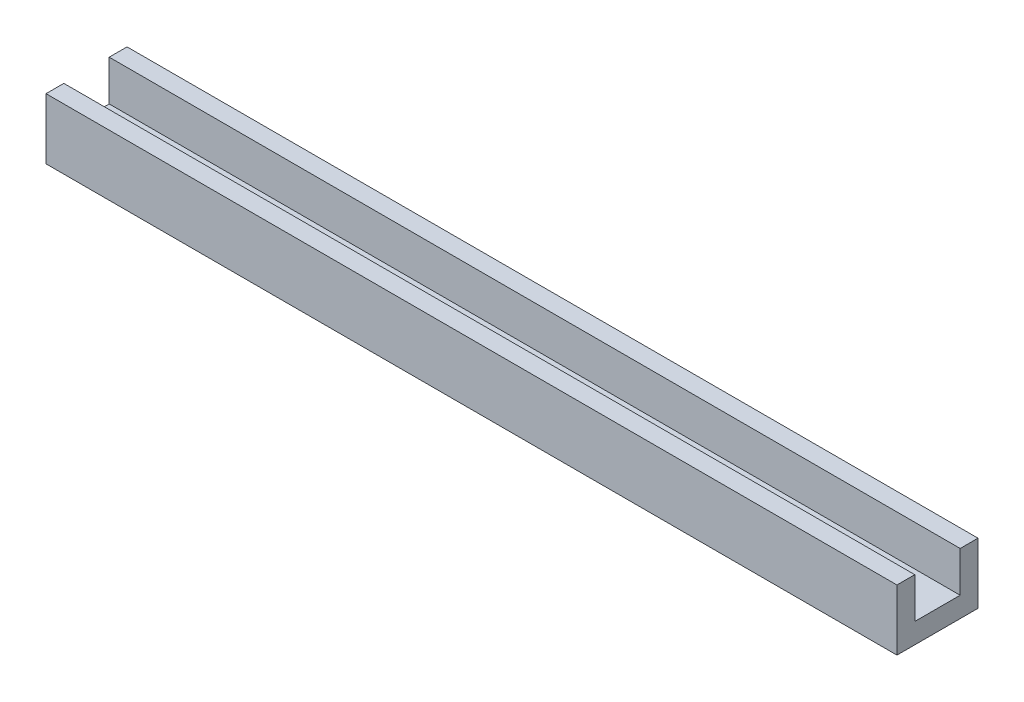
from build123d import *

# Parameters (mm, degrees)
SKETCH1_W           = 210
SKETCH1_H           = 20
BOSS_EXTRUDE1_DEPTH = 15
SKETCH2_W           = 210
SKETCH2_H           = 10
CUT_EXTRUDE1_DEPTH  = 10
SKETCH3_R           = 1.8
CUT_EXTRUDE2_DEPTH  = 6
SKETCH5_R           = 3.5
CUT_EXTRUDE3_DEPTH  = 3.6
SKETCH6_W           = 210
SKETCH6_H           = 10
CUT_EXTRUDE4_DEPTH  = 0.6
SKETCH7_W           = 210
SKETCH7_H           = 10
CUT_EXTRUDE5_DEPTH  = 0.6


with BuildPart() as part:
    # Sketch1 → Boss-Extrude1 (new body)
    with BuildSketch(Plane(origin=(0, 0, 0), x_dir=(1, 0, 0), z_dir=(0, 1, 0))):
        with Locations((105, 10)):
            Rectangle(SKETCH1_W, SKETCH1_H)
    extrude(amount=BOSS_EXTRUDE1_DEPTH)

    # Sketch2 → Cut-Extrude1 (cut)
    with BuildSketch(Plane(origin=(0, 15, 0), x_dir=(1, 0, 0), z_dir=(0, 1, 0))):
        with Locations((105, 10)):
            Rectangle(SKETCH2_W, SKETCH2_H)
    extrude(amount=-CUT_EXTRUDE1_DEPTH, mode=Mode.SUBTRACT)

    # Sketch3 → Cut-Extrude2 (cut, through all)
    with BuildSketch(Plane(origin=(0, 5, 0), x_dir=(1, 0, 0), z_dir=(0, 1, 0))):
        with Locations((25, 10)):
            Circle(SKETCH3_R)
    cut_extrude2 = extrude(amount=-CUT_EXTRUDE2_DEPTH, mode=Mode.SUBTRACT)

    # Sketch5 → Cut-Extrude3 (cut)
    with BuildSketch(Plane(origin=(0, 5, 0), x_dir=(1, 0, 0), z_dir=(0, 1, 0))):
        with Locations((25, 10)):
            Circle(SKETCH5_R)
    cut_extrude3 = extrude(amount=-CUT_EXTRUDE3_DEPTH, mode=Mode.SUBTRACT)

    # Mirror2: Cut-Extrude2, Cut-Extrude3 across plane
    add(cut_extrude2.mirror(Plane(origin=(58.611943839, 0, 0), x_dir=(0, 0, 1), z_dir=(1, 0, 0))), mode=Mode.SUBTRACT)
    add(cut_extrude3.mirror(Plane(origin=(58.611943839, 0, 0), x_dir=(0, 0, 1), z_dir=(1, 0, 0))), mode=Mode.SUBTRACT)

    # Sketch6 → Cut-Extrude4 (cut)
    with BuildSketch(Plane.XY.offset(-15)):
        with Locations((105, 10)):
            Rectangle(SKETCH6_W, SKETCH6_H)
    extrude(amount=-CUT_EXTRUDE4_DEPTH, mode=Mode.SUBTRACT)

    # Sketch7 → Cut-Extrude5 (cut)
    with BuildSketch(Plane(origin=(0, 0, -5), x_dir=(-1, 0, 0), z_dir=(0, 0, -1))):
        with Locations((-105, 10)):
            Rectangle(SKETCH7_W, SKETCH7_H)
    extrude(amount=-CUT_EXTRUDE5_DEPTH, mode=Mode.SUBTRACT)


solid = part.part
